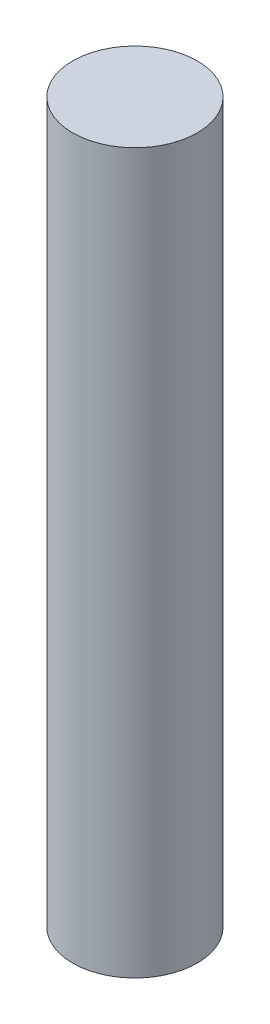
from build123d import *

# Parameters (mm, degrees)
SKETCH1_R      = 3.302
EXTRUDE1_DEPTH = 38.1


with BuildPart() as part:
    # Sketch1 → Extrude1 (new body)
    with BuildSketch(Plane(origin=(0, 0, 0), x_dir=(1, 0, 0), z_dir=(0, 1, 0))):
        Circle(SKETCH1_R)
    extrude(amount=EXTRUDE1_DEPTH)


solid = part.part
